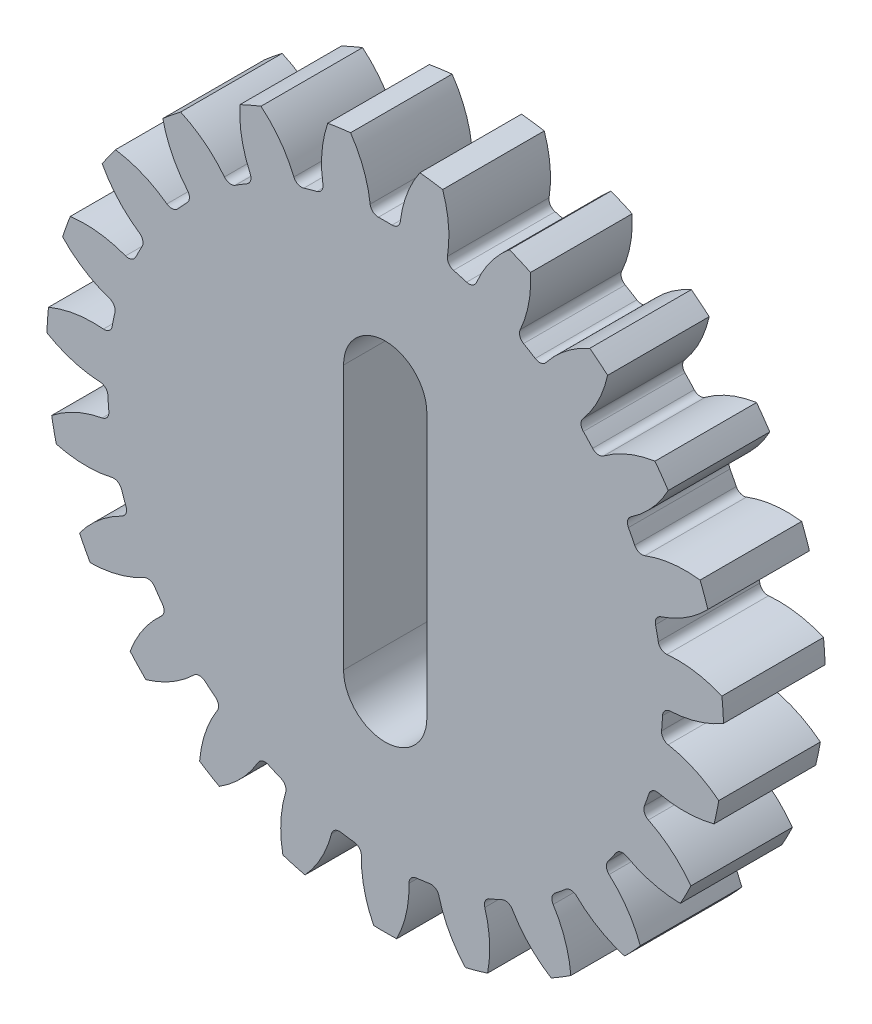
from build123d import *

# Parameters (mm, degrees)
SKBASE_R                                = 16.6625
BASE_DEPTH                              = 2.5
TOOTHPROFILE_DEPTH                      = 24.696578076
FILLETTOOTHPROFILE_R                    = 0.3999
CIRPATTERNTEETH_COUNT                   = 23
FILLETTOOTHPROFILE_OF_CIRPATTERNTEETH_R = 0.3999
CUT_EXTRUDE1_DEPTH                      = 25.082170779


with BuildPart() as part:
    # skBase → Base (new, symmetric)
    with BuildSketch(Plane.XY):
        Circle(SKBASE_R)
    extrude(amount=BASE_DEPTH, both=True)

    # skToothProfile → ToothProfile (cut, symmetric)
    with BuildSketch(Plane.XY):
        with BuildLine():
            ThreePointArc((-0.710888959, 13.64474395), (-1.229005772, 15.737103463), (-2.48866845, 17.486292792))
            ThreePointArc((-2.48866845, 17.486292792), (0, 17.6625), (2.48866845, 17.486292792))
            ThreePointArc((2.48866845, 17.486292792), (1.229005772, 15.737103463), (0.710888959, 13.64474395))
            ThreePointArc((0.710888959, 13.64474395), (0, 13.66325), (-0.710888959, 13.64474395))
        make_face()
    toothprofile = extrude(amount=TOOTHPROFILE_DEPTH, both=True, mode=Mode.SUBTRACT)

    # FilletToothProfile
    fillettoothprofile_edges = [part.edges().sort_by_distance(p)[0] for p in [
        (-0.710888959, 13.64474395, 0),
        (0.710888959, 13.64474395, 0),
    ]]
    fillet(fillettoothprofile_edges, radius=FILLETTOOTHPROFILE_R)

    # CirPatternTeeth: ToothProfile ×23 about axis
    cirpatternteeth_axis = Axis((0, 0, 0), (0, 0, 1))
    for i in range(1, CIRPATTERNTEETH_COUNT):
        add(toothprofile.rotate(cirpatternteeth_axis, i * 360 / CIRPATTERNTEETH_COUNT), mode=Mode.SUBTRACT)

    # FilletToothProfile of CirPatternTeeth
    fillettoothprofile_of_cirpatternteeth_edges = [part.edges().sort_by_distance(p)[0] for p in [
        (-4.365835129, 12.946964285, 0),
        (-2.996780593, 13.330555376, 0),
        (-7.696987279, 11.288967507, 0),
        (-6.482192638, 12.027700494, 0),
        (-10.457289095, 8.793719654, 0),
        (-9.486850109, 9.832806089, 0),
        (-12.442021617, 5.646281842, 0),
        (-11.787911306, 6.908657438, 0),
        (-13.503986315, 2.080085136, 0),
        (-13.214717048, 3.472125271, 0),
        (-13.564422124, -1.640381969, 0),
        (-13.66144768, -0.221918544, 0),
        (-12.618846797, -5.239189448, 0),
        (-13.094971235, -3.899503676, 0),
        (-10.737389331, -8.449430213, 0),
        (-11.557300678, -7.28788046, 0),
        (-8.059588818, -11.033015392, 0),
        (-9.162478002, -10.135748489, 0),
        (-4.784045473, -12.798332293, 0),
        (-6.088116247, -12.231894421, 0),
        (-1.153691361, -13.614455436, 0),
        (-2.562226762, -13.420856701, 0),
        (2.562226762, -13.420856701, 0),
        (1.153691361, -13.614455436, 0),
        (6.088116247, -12.231894421, 0),
        (4.784045473, -12.798332293, 0),
        (9.162478002, -10.135748489, 0),
        (8.059588818, -11.033015392, 0),
        (11.557300678, -7.28788046, 0),
        (10.737389331, -8.449430213, 0),
        (13.094971235, -3.899503676, 0),
        (12.618846797, -5.239189448, 0),
        (13.66144768, -0.221918544, 0),
        (13.564422124, -1.640381969, 0),
        (13.214717048, 3.472125271, 0),
        (13.503986315, 2.080085136, 0),
        (11.787911306, 6.908657438, 0),
        (12.442021617, 5.646281842, 0),
        (9.486850109, 9.832806089, 0),
        (10.457289095, 8.793719654, 0),
        (6.482192638, 12.027700494, 0),
        (7.696987279, 11.288967507, 0),
        (2.996780593, 13.330555376, 0),
        (4.365835129, 12.946964285, 0),
    ]]
    fillet(fillettoothprofile_of_cirpatternteeth_edges, radius=FILLETTOOTHPROFILE_OF_CIRPATTERNTEETH_R)

    # Sketch5 → Cut-Extrude1 (cut, through all)
    with BuildSketch(Plane(origin=(0, 0, -2.5), x_dir=(-1, 0, 0), z_dir=(0, 0, -1))):
        with BuildLine():
            Line((2.05, 6.5), (2.05, -6.5))
            ThreePointArc((2.05, -6.5), (0, -8.55), (-2.05, -6.5))
            Line((-2.05, -6.5), (-2.05, 6.5))
            ThreePointArc((-2.05, 6.5), (0, 8.55), (2.05, 6.5))
        make_face()
    extrude(amount=-CUT_EXTRUDE1_DEPTH, mode=Mode.SUBTRACT)


solid = part.part
